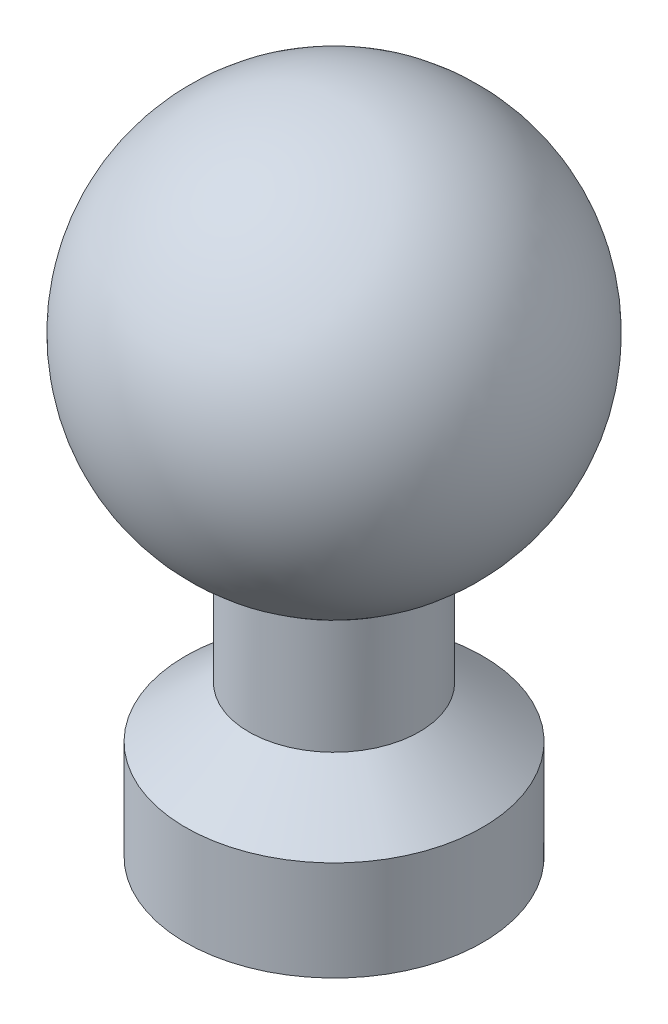
from build123d import *


with BuildPart() as part:
    # Esquisse1 → Révolution1 (revolve)
    with BuildSketch(Plane.XY, mode=Mode.PRIVATE) as r_volution1_sk:
        with BuildLine():
            Line((0, 34.362064325), (0, 0))
            Line((0, 0), (7.770551536, 0))
            Line((7.770551536, 0), (7.770551536, 5.216592512))
            Line((7.770551536, 5.216592512), (4.463105144, 7.891594312))
            Line((4.463105144, 7.891594312), (4.463105144, 14.085553133))
            ThreePointArc((4.463105144, 14.085553133), (10.380946653, 26.017588847), (0, 34.362064325))
        make_face()
    revolve(r_volution1_sk.sketch.rotate(Axis((0, 34.362064325, 0), (0, -1, 0)), 180), axis=Axis((0, 34.362064325, 0), (0, -1, 0)))  # turned: the seam where the file's is


solid = part.part
